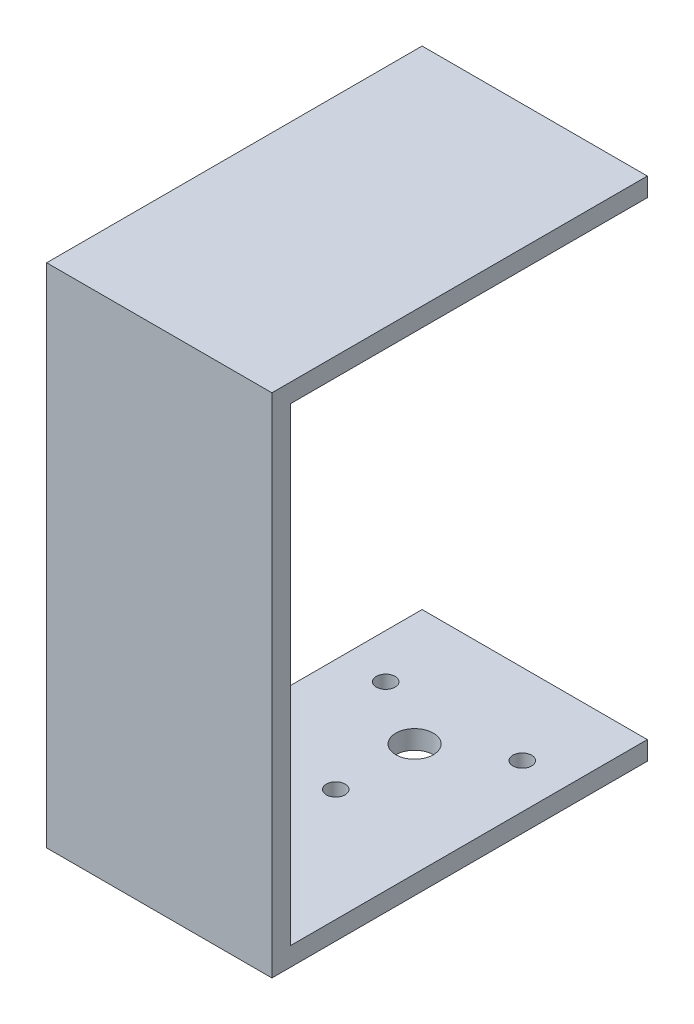
from build123d import *

# Parameters (mm, degrees)
SKETCH1_W           = 60
SKETCH1_H           = 100
BOSS_EXTRUDE1_DEPTH = 5
SKETCH2_W           = 60
SKETCH2_H           = 5
BOSS_EXTRUDE2_DEPTH = 130
SKETCH3_W           = 60
SKETCH3_H           = 5
BOSS_EXTRUDE3_DEPTH = 55
SKETCH9_W           = 60
SKETCH9_H           = 40
CUT_EXTRUDE1_DEPTH  = 55
SKETCH11_W          = 60
SKETCH11_H          = 5
BOSS_EXTRUDE4_DEPTH = 40
SKETCH12_W          = 60
SKETCH12_H          = 5
BOSS_EXTRUDE5_DEPTH = 40
SKETCH13_R          = 5
CUT_EXTRUDE2_DEPTH  = 40
SKETCH14_R          = 2.5
CUT_EXTRUDE3_DEPTH  = 40


with BuildPart() as part:
    # Sketch1 → Boss-Extrude1 (new body)
    with BuildSketch(Plane(origin=(0, 0, 0), x_dir=(1, 0, 0), z_dir=(0, 1, 0))):
        with Locations((-30, 50)):
            Rectangle(SKETCH1_W, SKETCH1_H)
    extrude(amount=BOSS_EXTRUDE1_DEPTH)

    # Sketch2 → Boss-Extrude2 (add)
    with BuildSketch(Plane(origin=(0, 5, 0), x_dir=(1, 0, 0), z_dir=(0, 1, 0))):
        with Locations((-30, 2.5)):
            Rectangle(SKETCH2_W, SKETCH2_H)
    extrude(amount=BOSS_EXTRUDE2_DEPTH)

    # Sketch3 → Boss-Extrude3 (add)
    with BuildSketch(Plane(origin=(0, 0, -5), x_dir=(-1, 0, 0), z_dir=(0, 0, -1))):
        with Locations((30, 132.5)):
            Rectangle(SKETCH3_W, SKETCH3_H)
    extrude(amount=BOSS_EXTRUDE3_DEPTH)

    # Sketch9 → Cut-Extrude1 (cut)
    with BuildSketch(Plane(origin=(0, 0, 0), x_dir=(-1, 0, 0), z_dir=(0, -1, 0))):
        with Locations((30, 80)):
            Rectangle(SKETCH9_W, SKETCH9_H)
    extrude(amount=-CUT_EXTRUDE1_DEPTH, mode=Mode.SUBTRACT)

    # Sketch11 → Boss-Extrude4 (add)
    with BuildSketch(Plane(origin=(0, 0, -60), x_dir=(-1, 0, 0), z_dir=(0, 0, -1))):
        with Locations((30, 132.5)):
            Rectangle(SKETCH11_W, SKETCH11_H)
    extrude(amount=BOSS_EXTRUDE4_DEPTH)

    # Sketch12 → Boss-Extrude5 (add)
    with BuildSketch(Plane(origin=(0, 0, -60), x_dir=(-1, 0, 0), z_dir=(0, 0, -1))):
        with Locations((30, 2.5)):
            Rectangle(SKETCH12_W, SKETCH12_H)
    extrude(amount=BOSS_EXTRUDE5_DEPTH)

    # Sketch13 → Cut-Extrude2 (cut)
    with BuildSketch(Plane.XZ):
        with Locations((-30, -68)):
            Circle(SKETCH13_R)
    extrude(amount=-CUT_EXTRUDE2_DEPTH, mode=Mode.SUBTRACT)

    # Sketch14 → Cut-Extrude3 (cut)
    with BuildSketch(Plane.XZ):
        with Locations((-30, -47)):
            Circle(SKETCH14_R)
        with Locations((-48.186533479, -78.5)):
            Circle(SKETCH14_R)
        with Locations((-11.813466521, -78.5)):
            Circle(SKETCH14_R)
    extrude(amount=-CUT_EXTRUDE3_DEPTH, mode=Mode.SUBTRACT)


solid = part.part
